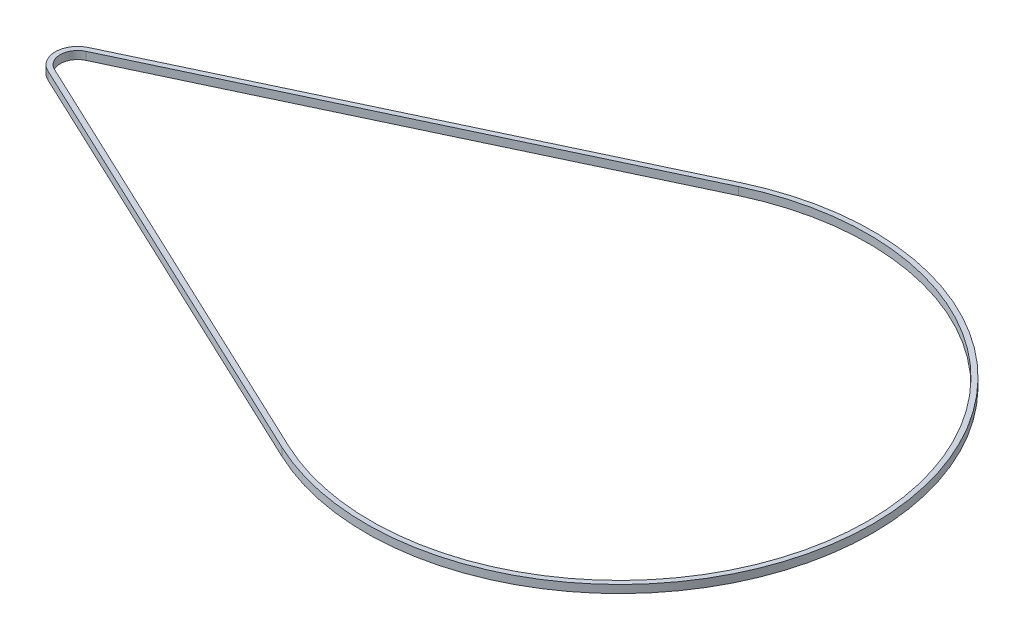
from build123d import *

# Parameters (mm, degrees)
BOSS_EXTRUDE1_DEPTH = 3.175


with BuildPart() as part:
    # Sketch1 → Boss-Extrude1 (new body)
    with BuildSketch(Plane(origin=(0, 0, 0), x_dir=(1, 0, 0), z_dir=(0, 1, 0))):
        with BuildLine():
            Line((-43.513761468, 92.252656129), (-221.839449541, 8.139940247))
            ThreePointArc((-221.839449541, 8.139940247), (-227, 0), (-221.839449541, -8.139940247))
            Line((-221.839449541, -8.139940247), (-43.513761468, -92.252656129))
            ThreePointArc((-43.513761468, -92.252656129), (102, 0), (-43.513761468, 92.252656129))
        make_face()
        with BuildLine():
            Line((-42.660550459, 90.443780519), (-220.986238532, 6.331064636))
            ThreePointArc((-220.986238532, 6.331064636), (-225, 0), (-220.986238532, -6.331064636))
            Line((-220.986238532, -6.331064636), (-42.660550459, -90.443780519))
            ThreePointArc((-42.660550459, -90.443780519), (100, 0), (-42.660550459, 90.443780519))
        make_face(mode=Mode.SUBTRACT)
    extrude(amount=BOSS_EXTRUDE1_DEPTH)


solid = part.part
